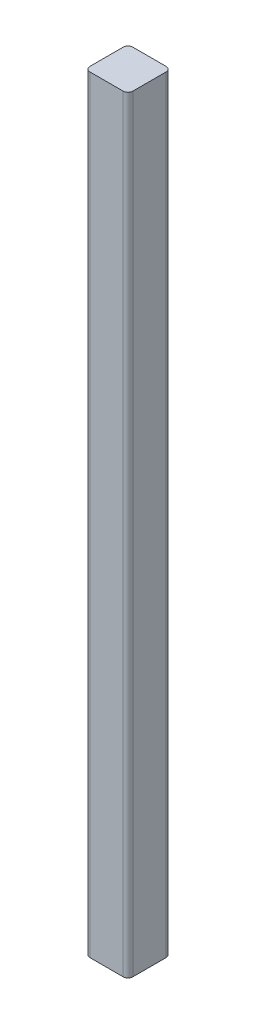
from build123d import *

# Parameters (mm, degrees)
SKETCH1_W           = 40
SKETCH1_H           = 40
BOSS_EXTRUDE1_DEPTH = 715
FILLET1_R           = 4.5


with BuildPart() as part:
    # Sketch1 → Boss-Extrude1 (new body)
    with BuildSketch(Plane(origin=(0, 0, 0), x_dir=(1, 0, 0), z_dir=(0, 1, 0))):
        Rectangle(SKETCH1_W, SKETCH1_H)
    extrude(amount=BOSS_EXTRUDE1_DEPTH)

    # Fillet1
    fillet1_edges = [part.edges().sort_by_distance(p)[0] for p in [
        (20, 357.5, 20),
        (-20, 357.5, 20),
        (-20, 357.5, -20),
        (20, 357.5, -20),
    ]]
    fillet(fillet1_edges, radius=FILLET1_R)


solid = part.part
